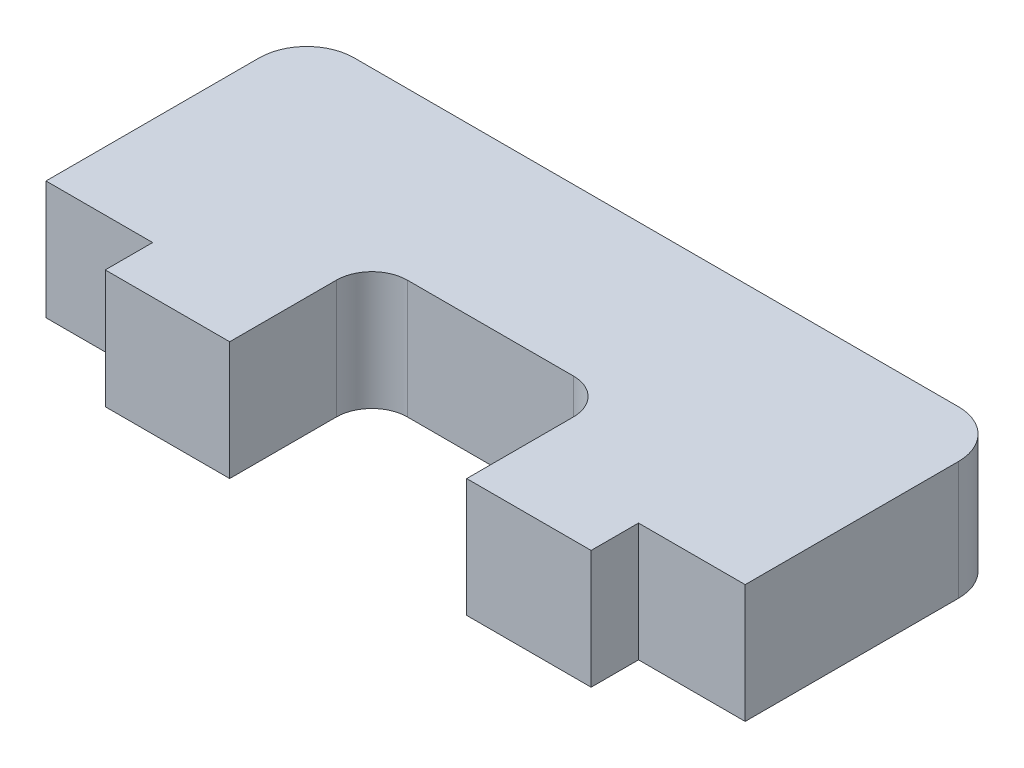
from build123d import *

# Parameters (mm, degrees)
SKETCH1_W           = 29.5
SKETCH1_H           = 13
BOSS_EXTRUDE1_DEPTH = 5
SKETCH2_W           = 10
SKETCH2_H           = 6
CUT_EXTRUDE1_DEPTH  = 6
FILLET1_R           = 2
FILLET2_R           = 1.5
SKETCH3_OUTSIDE_W   = 38.024
SKETCH3_OUTSIDE_H   = 13.524
SKETCH3_OUTSIDE_W_2 = 20.5
SKETCH3_OUTSIDE_H_2 = 5
CUT_EXTRUDE2_DEPTH  = 2


with BuildPart() as part:
    # Sketch1 → Boss-Extrude1 (new body)
    with BuildSketch(Plane(origin=(0, 0, 0), x_dir=(1, 0, 0), z_dir=(0, 1, 0))):
        Rectangle(SKETCH1_W, SKETCH1_H)
    extrude(amount=BOSS_EXTRUDE1_DEPTH)

    # Sketch2 → Cut-Extrude1 (cut, through all)
    with BuildSketch(Plane(origin=(0, 5, 0), x_dir=(1, 0, 0), z_dir=(0, 1, 0))):
        with Locations((0, -3.5)):
            Rectangle(SKETCH2_W, SKETCH2_H)
    extrude(amount=-CUT_EXTRUDE1_DEPTH, mode=Mode.SUBTRACT)

    # Fillet1
    fillet1_edges = [part.edges().sort_by_distance(p)[0] for p in [
        (-14.75, 2.5, -6.5),
        (14.75, 2.5, -6.5),
    ]]
    fillet(fillet1_edges, radius=FILLET1_R)

    # Fillet2
    fillet2_edges = [part.edges().sort_by_distance(p)[0] for p in [
        (-5, 2.5, 0.5),
        (5, 2.5, 0.5),
    ]]
    fillet(fillet2_edges, radius=FILLET2_R)

    # Sketch3 outside → Cut-Extrude2 (cut)
    with BuildSketch(Plane.XY.offset(6.5)):
        with Locations((0, 2.5)):
            Rectangle(SKETCH3_OUTSIDE_W, SKETCH3_OUTSIDE_H)
        with Locations((0, 2.5)):
            Rectangle(SKETCH3_OUTSIDE_W_2, SKETCH3_OUTSIDE_H_2, mode=Mode.SUBTRACT)
    extrude(amount=-CUT_EXTRUDE2_DEPTH, mode=Mode.SUBTRACT)


solid = part.part
